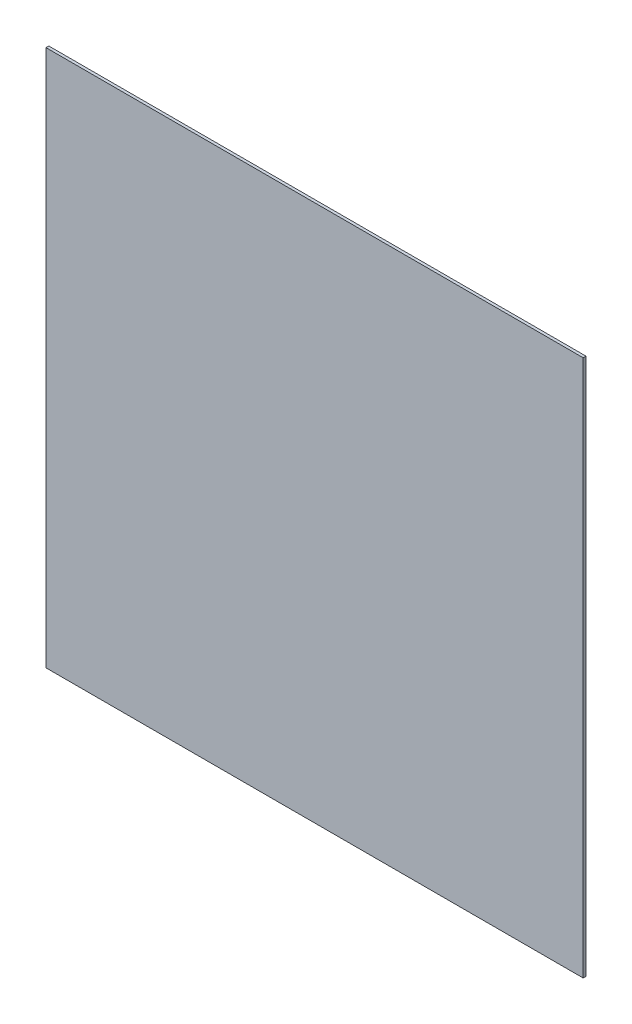
from build123d import *

# Parameters (mm, degrees)
SKETCH1_W           = 474
SKETCH1_H           = 474
BOSS_EXTRUDE1_DEPTH = 2.5


with BuildPart() as part:
    # Sketch1 → Boss-Extrude1 (new body)
    with BuildSketch(Plane.XY):
        with Locations((-237, 237)):
            Rectangle(SKETCH1_W, SKETCH1_H)
    extrude(amount=BOSS_EXTRUDE1_DEPTH)


solid = part.part
